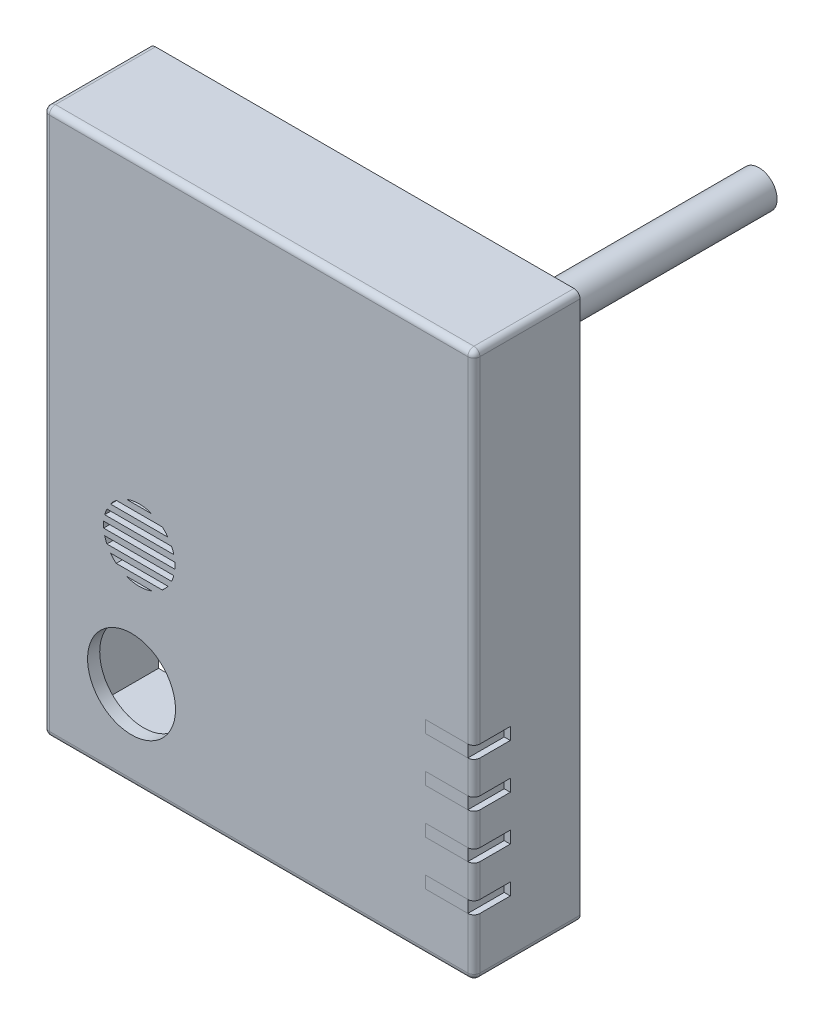
from build123d import *

# Parameters (mm, degrees)
SKETCH2_W                    = 71
SKETCH2_H                    = 90
BOSS_EXTRUDE1_DEPTH          = 17.5
SHELL1_T                     = -3
SHELL1_THICKNESS_2_FACE_W    = 65
SHELL1_THICKNESS_2_FACE_H    = 84
SHELL1_THICKNESS_2_DEPTH     = 1
CUT_EXTRUDE10_DEPTH          = 1.5
SKETCH4_W                    = 7.2
SKETCH4_H                    = 2.2
CUT_EXTRUDE2_DEPTH           = 2
SKETCH5_W                    = 8
SKETCH5_H                    = 2
CUT_EXTRUDE3_DEPTH           = 2
SKETCH6_W                    = 6
SKETCH6_H                    = 2
CUT_EXTRUDE4_DEPTH           = 3
LPATTERN1_COUNT              = 4
LPATTERN1_PITCH              = 7.4
SKETCH7_R                    = 7.25
CUT_EXTRUDE5_DEPTH           = 2
CUT_EXTRUDE7_DEPTH           = 2
FILLET1_R                    = 1
FILLET2_R                    = 1
SKETCH9_R                    = 3
BOSS_EXTRUDE2_DEPTH          = 62
F_3_0_3_DIAMETER_HOLE1_D     = 3
F_3_0_3_DIAMETER_HOLE1_DEPTH = 6
F_3_0_3_DIAMETER_HOLE1_TIP   = 0.901290929
CUT_EXTRUDE13_START          = -1.5
CUT_EXTRUDE13_DEPTH          = 68
SKETCH35_W                   = 7
SKETCH35_H                   = 2
BOSS_EXTRUDE3_DEPTH          = 6
LPATTERN2_COUNT              = 4
LPATTERN2_PITCH              = 7.4


with BuildPart() as part:
    # Sketch2 → Boss-Extrude1 (new body)
    with BuildSketch(Plane.XY):
        Rectangle(SKETCH2_W, SKETCH2_H)
    extrude(amount=BOSS_EXTRUDE1_DEPTH)

    # Shell1
    shell1_openings = [part.faces().sort_by_distance(p)[0] for p in [
        (0, 0, 0),
    ]]
    offset(amount=SHELL1_T, openings=shell1_openings, kind=Kind.INTERSECTION)

    # Shell1 thickness 2 face (on inner face of the shell) → Shell1 thickness 2 (cut)
    with BuildSketch(Plane.XY.offset(14.5)):
        Rectangle(SHELL1_THICKNESS_2_FACE_W, SHELL1_THICKNESS_2_FACE_H)
    extrude(amount=SHELL1_THICKNESS_2_DEPTH, mode=Mode.SUBTRACT)

    # Sketch3 → Cut-Extrude10 (cut)
    with BuildSketch(Plane(origin=(0, 0, 0), x_dir=(-1, 0, 0), z_dir=(0, 0, -1))):
        Polygon((-32.5, -42), (-34, -42), (-34, 43.5), (34, 43.5), (34, -42), (32.5, -42), align=None)
    extrude(amount=-CUT_EXTRUDE10_DEPTH, mode=Mode.SUBTRACT)

    # Sketch4 → Cut-Extrude2 (cut)
    with BuildSketch(Plane.XZ.offset(45)):
        with Locations((3.6, 6.6)):
            Rectangle(SKETCH4_W, SKETCH4_H)
    extrude(amount=-CUT_EXTRUDE2_DEPTH, mode=Mode.SUBTRACT)

    # Sketch5 → Cut-Extrude3 (cut)
    with BuildSketch(Plane.XY.offset(17.5)):
        with Locations((31.5, -34.5)):
            Rectangle(SKETCH5_W, SKETCH5_H)
    cut_extrude3 = extrude(amount=-CUT_EXTRUDE3_DEPTH, mode=Mode.SUBTRACT)

    # Sketch6 → Cut-Extrude4 (cut)
    with BuildSketch(Plane(origin=(35.5, 0, 0), x_dir=(0, 0, -1), z_dir=(1, 0, 0))):
        with Locations((-14.5, -34.5)):
            Rectangle(SKETCH6_W, SKETCH6_H)
    cut_extrude4 = extrude(amount=-CUT_EXTRUDE4_DEPTH, mode=Mode.SUBTRACT)

    # LPattern1: Cut-Extrude3, Cut-Extrude4 ×4
    with Locations(*[(0, i * LPATTERN1_PITCH, 0) for i in range(1, LPATTERN1_COUNT)]):
        add(cut_extrude3, mode=Mode.SUBTRACT)
        add(cut_extrude4, mode=Mode.SUBTRACT)

    # Sketch7 → Cut-Extrude5 (cut)
    with BuildSketch(Plane.XY.offset(17.5)):
        with Locations((-20.95, -30.48)):
            Circle(SKETCH7_R)
    extrude(amount=-CUT_EXTRUDE5_DEPTH, mode=Mode.SUBTRACT)

    # Sketch8 → Cut-Extrude7 (cut)
    with BuildSketch(Plane.XY.offset(17.5)):
        with BuildLine():
            Line((-25.57, -10), (-13.79, -10))
            ThreePointArc((-13.79, -10), (-13.795317596, -9.749774092), (-13.811260783, -9.5))
            Line((-13.811260783, -9.5), (-25.548739217, -9.5))
            ThreePointArc((-25.548739217, -9.5), (-25.564682404, -9.749774092), (-25.57, -10))
        make_face()
        with BuildLine():
            ThreePointArc((-13.811260783, -10.5), (-13.795317596, -10.250225908), (-13.79, -10))
            Line((-13.79, -10), (-25.57, -10))
            ThreePointArc((-25.57, -10), (-25.564682404, -10.250225908), (-25.548739217, -10.5))
            Line((-25.548739217, -10.5), (-13.811260783, -10.5))
        make_face()
        with BuildLine():
            Line((-25.375796696, -8.5), (-13.984203304, -8.5))
            ThreePointArc((-13.984203304, -8.5), (-14.142923584, -7.991795636), (-14.346886463, -7.5))
            Line((-14.346886463, -7.5), (-25.013113537, -7.5))
            ThreePointArc((-25.013113537, -7.5), (-25.217076416, -7.991795636), (-25.375796696, -8.5))
        make_face()
        with BuildLine():
            ThreePointArc((-14.346886463, -12.5), (-14.142923584, -12.008204364), (-13.984203304, -11.5))
            Line((-13.984203304, -11.5), (-25.375796696, -11.5))
            ThreePointArc((-25.375796696, -11.5), (-25.217076416, -12.008204364), (-25.013113537, -12.5))
            Line((-25.013113537, -12.5), (-14.346886463, -12.5))
        make_face()
        with BuildLine():
            ThreePointArc((-15.879723694, -14.5), (-15.382024632, -14.027344999), (-14.942690637, -13.5))
            Line((-14.942690637, -13.5), (-24.417309363, -13.5))
            ThreePointArc((-24.417309363, -13.5), (-23.977975368, -14.027344999), (-23.480276306, -14.5))
            Line((-23.480276306, -14.5), (-15.879723694, -14.5))
        make_face()
        with BuildLine():
            Line((-24.417309363, -6.5), (-14.942690637, -6.5))
            ThreePointArc((-14.942690637, -6.5), (-15.382024632, -5.972655001), (-15.879723694, -5.5))
            Line((-15.879723694, -5.5), (-23.480276306, -5.5))
            ThreePointArc((-23.480276306, -5.5), (-23.977975368, -5.972655001), (-24.417309363, -6.5))
        make_face()
        with BuildLine():
            Line((-21.787629, -4.5), (-17.572371, -4.5))
            ThreePointArc((-17.572371, -4.5), (-19.68, -4.11), (-21.787629, -4.5))
        make_face()
        with BuildLine():
            ThreePointArc((-21.787629, -15.5), (-19.68, -15.89), (-17.572371, -15.5))
            Line((-17.572371, -15.5), (-21.787629, -15.5))
        make_face()
    extrude(amount=-CUT_EXTRUDE7_DEPTH, mode=Mode.SUBTRACT)

    # Fillet1
    fillet1_edges = [part.edges().sort_by_distance(p)[0] for p in [
        (0, 45, 17.5),
        (35.5, -16, 17.5),
        (35.5, -23.4, 17.5),
        (35.5, -30.8, 17.5),
        (32.5, -16, 15.5),
        (32.5, -23.4, 15.5),
        (32.5, -30.8, 15.5),
        (-35.5, 0, 17.5),
        (32.5, 15.35, 15.5),
        (0, 42, 15.5),
        (0, -45, 17.5),
        (35.5, -40.25, 17.5),
        (32.5, -38.75, 15.5),
        (35.5, 16.85, 17.5),
        (-35.5, -45, 8.75),
        (-35.5, 45, 8.75),
        (35.5, 45, 8.75),
        (35.5, -45, 8.75),
    ]]
    fillet(fillet1_edges, radius=FILLET1_R)

    # Fillet2
    fillet2_edges = [part.edges().sort_by_distance(p)[0] for p in [
        (-0.5, -42, 15.5),
        (-32.5, -0.5, 15.5),
        (32.5, -42, 8),
        (32.207106781, -42, 15.207106781),
        (-32.5, 42, 8),
        (-32.5, 41.707106781, 15.207106781),
    ]]
    fillet(fillet2_edges, radius=FILLET2_R)

    # Sketch9 → Boss-Extrude2 (add)
    with BuildSketch(Plane.XY.offset(17.5)):
        with Locations((20.5, 30)):
            Circle(SKETCH9_R)
    extrude(amount=-BOSS_EXTRUDE2_DEPTH)

    # Ø3.0 (3) Diameter Hole1
    with Locations(Plane(origin=(20.5, 30, -44.5), x_dir=(-1, 0, 0), z_dir=(0, 0, -1))):
        with Locations((0, 0)):
            Hole(F_3_0_3_DIAMETER_HOLE1_D / 2, depth=F_3_0_3_DIAMETER_HOLE1_DEPTH)
            with Locations((0, 0, -(F_3_0_3_DIAMETER_HOLE1_DEPTH + F_3_0_3_DIAMETER_HOLE1_TIP / 2))):  # 118° drill point
                Cone(0, F_3_0_3_DIAMETER_HOLE1_D / 2, F_3_0_3_DIAMETER_HOLE1_TIP, mode=Mode.SUBTRACT)

    # Sketch34 → Cut-Extrude13 (cut)
    with BuildSketch(Plane(origin=(35.5, 0, 0), x_dir=(0, 0, -1), z_dir=(1, 0, 0)).offset(CUT_EXTRUDE13_START)):
        Polygon((0, -42), (-1.5, -42), (-1.5, -44), (0, -43.5), align=None)
    extrude(amount=-CUT_EXTRUDE13_DEPTH, mode=Mode.SUBTRACT)


with BuildPart() as body_2:
    # Sketch35 → Boss-Extrude3 (new body)
    with BuildSketch(Plane.XY.offset(17.5)):
        with Locations((31, -34.5)):
            Rectangle(SKETCH35_W, SKETCH35_H)
    boss_extrude3 = extrude(amount=-BOSS_EXTRUDE3_DEPTH)


with BuildPart() as lpattern2_1:
    # LPattern2: Boss-Extrude3 ×4
    with Locations(*[(0, i * LPATTERN2_PITCH, 0) for i in range(1, LPATTERN2_COUNT)]):
        add(boss_extrude3)


solid = Compound([part.part, body_2.part, lpattern2_1.part])
